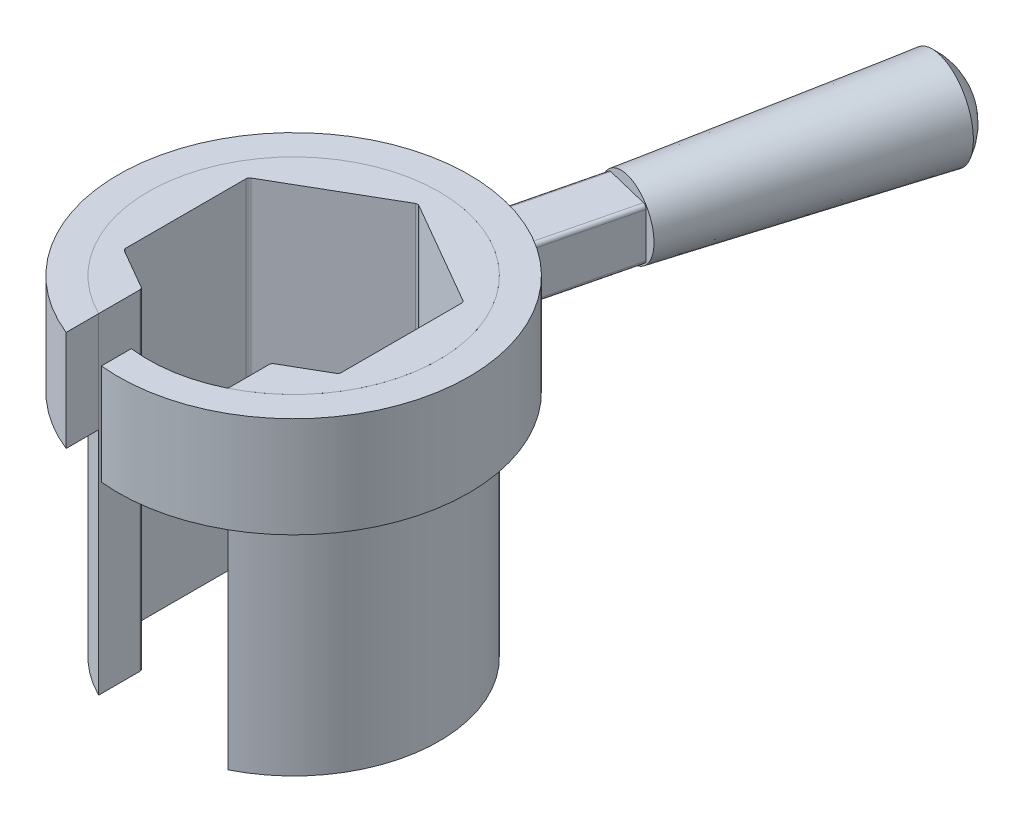
from build123d import *

# Parameters (mm, degrees)
EXTRUDE3_DEPTH                  = 46
EXTRUDE4_DEPTH                  = 14
SKETCH22_W                      = 7.200000000000002
SKETCH22_H                      = 7.199999999999999
EXTRUDE5_DEPTH                  = 14
EXTRUDE5_DIRECTION_2_REACH      = 75.07
EXTRUDE5_DIRECTION_2_END_RADIUS = 24.39
SKETCH23_R                      = 5.091168824543142
EXTRUDE6_DEPTH                  = 36
EXTRUDE6_DRAFT                  = -2.0000000000000044
DOME1_FACE_RADIUS               = 6.348316526
DOME1_HEIGHT                    = 3
CUT_EXTRUDE7_DEPTH              = 92.63173419897609
FILLET2_R                       = 0.5
FILLET3_R                       = 0.5


with BuildPart() as part:
    # Sketch20 → Extrude3 (new body)
    with BuildSketch(Plane(origin=(0, 0, 0), x_dir=(1, 0, 0), z_dir=(0, 1, 0))):
        with BuildLine():
            Line((-9, -12), (-8.999999999999998, -18.14007993367174))
            ThreePointArc((-8.999999999999998, -18.14007993367174), (5.74e-15, 20.25), (8.999999999999998, -18.14007993367174))
            Line((8.999999999999998, -18.14007993367174), (9, -12))
            ThreePointArc((9, -12), (9.2e-16, 15), (-9, -12))
        make_face()
    extrude(amount=EXTRUDE3_DEPTH)

    # Sketch24 → Cut-Extrude7 (cut, through all)
    with BuildSketch(Plane.XZ):
        Polygon((-15, 8.660254037844384), (-15.000000000000002, -8.660254037844384), (-1.98e-15, -17.32050807568877), (15, -8.660254037844378), (15, 8.660254037844389), (1.7e-15, 17.320508075688775), align=None)
    extrude(amount=-CUT_EXTRUDE7_DEPTH, mode=Mode.SUBTRACT)

    # Fillet3
    fillet3_edges = [part.edges().sort_by_distance(p)[0] for p in [
        (-9, 23, 12.124355652982139),
        (-15, 23, 8.660254037844384),
        (9, 23, 12.124355652982143),
        (15, 23, 8.660254037844389),
        (15, 23, -8.660254037844378),
        (-1.98e-15, 23, -17.32050807568877),
        (-15.000000000000002, 23, -8.660254037844384),
    ]]
    fillet(fillet3_edges, radius=FILLET3_R)


with BuildPart() as body_2:
    # Sketch21 → Extrude4 (new body)
    with BuildSketch(Plane(origin=(0, 45.998999999999995, 0), x_dir=(-1, 0, 0), z_dir=(0, 1, 0))):
        with BuildLine():
            Line((2.5, 20.095086464108586), (2.5, 24.261535400711967))
            ThreePointArc((2.5, 24.261535400711967), (-5.804889624821732, -23.689140052852004), (8.999999999999996, 22.668747208436557))
            Line((8.999999999999996, 22.668747208436557), (8.999999999999996, 18.14007993367174))
            ThreePointArc((8.999999999999996, 18.14007993367174), (-5.8324962609086, -19.39186652611056), (2.5, 20.095086464108586))
        make_face()
    extrude(amount=-EXTRUDE4_DEPTH)


with BuildPart() as body_3:
    # Sketch22 → Extrude5 (new body)
    with BuildSketch(Plane(origin=(5.8048896248217305, 45.998999999999995, -23.689140052852004), x_dir=(-0.9712644548114803, 0, -0.23800285464623744), z_dir=(0.23800285464623744, 0, -0.9712644548114803))):
        with Locations((0, -7)):
            Rectangle(SKETCH22_W, SKETCH22_H)
    extrude(amount=EXTRUDE5_DEPTH)

    # Extrude5 direction 2: up to this cylinder (the profile starts outside it)
    extrude5_direction_2_end = Plane(origin=(0, 38.999, 0), z_dir=(0, 1, 0)) * Cylinder(EXTRUDE5_DIRECTION_2_END_RADIUS, 199.92, mode=Mode.PRIVATE)
    # Sketch22 → Extrude5 direction 2 (add, up to the surface)
    with BuildSketch(Plane(origin=(5.8048896248217305, 45.998999999999995, -23.689140052852004), x_dir=(-0.9712644548114803, 0, -0.23800285464623744), z_dir=(0.23800285464623744, 0, -0.9712644548114803)), mode=Mode.PRIVATE) as extrude5_direction_2_sk1:
        with Locations((0, -7)):
            Rectangle(SKETCH22_W, SKETCH22_H)
    extrude5_direction_2_tool1 = extrude(extrude5_direction_2_sk1.sketch, amount=-EXTRUDE5_DIRECTION_2_REACH, mode=Mode.PRIVATE) - extrude5_direction_2_end
    add(extrude5_direction_2_tool1.solids().sort_by_distance((5.80489, 38.999, -23.68914))[0])
    add(extrude5_direction_2_tool1.solids().sort_by_distance((5.80489, 38.999, -23.68914))[1])


with BuildPart() as extrude6_tool:
    # Sketch23 → Extrude6 (with draft: the straight prism first)
    with BuildSketch(Plane(origin=(9.136929589869046, 0, -37.28684242021275), x_dir=(-0.9712644548114804, -1.6827536930173812e-15, -0.2380028546462371), z_dir=(0.2380028546462371, 0, -0.9712644548114804))):
        with Locations((0, 38.998999999999924)):
            Circle(SKETCH23_R)
    extrude(amount=EXTRUDE6_DEPTH)
    # Extrude6: the draft: its side faces are tilted about the plane it starts from
    extrude6_sides = [extrude6_tool.faces().sort_by_distance(p)[0] for p in [
        (18.365852286, 38.999, -53.557889893),
    ]]
    draft(extrude6_sides, Plane(origin=(9.136929589869046, 0, -37.28684242021275), x_dir=(-0.9712644548114804, -1.6827536930173812e-15, -0.2380028546462371), z_dir=(0.2380028546462371, 0, -0.9712644548114804)), EXTRUDE6_DRAFT)


with BuildPart() as body_3_1:
    add(body_3.part)

    # Extrude6: add extrude6_tool
    add(extrude6_tool.part)

    # Dome1: a dome of height H over a round flat face of radius A is a cap of a sphere of radius (A * A + H * H) / (2 * H)
    dome1_r = (DOME1_FACE_RADIUS * DOME1_FACE_RADIUS + DOME1_HEIGHT * DOME1_HEIGHT) / (2 * DOME1_HEIGHT)
    dome1_base = Plane((17.705032357, 38.999, -72.252362793), z_dir=(0.238002854646, 0, -0.971264454811))
    with Locations(dome1_base.offset(DOME1_HEIGHT - dome1_r)):
        dome1_ball = Sphere(dome1_r, mode=Mode.PRIVATE)
    add(split(dome1_ball, bisect_by=dome1_base, keep=Keep.TOP, mode=Mode.PRIVATE))

    # Fillet2
    fillet2_edges = [body_3_1.edges().sort_by_distance(p)[0] for p in [
        (10.935670926101846, 42.599, -29.501446402710464),
        (3.942566851459185, 42.599, -31.215066956163376),
        (3.9425668514591843, 35.398999999999994, -31.215066956163376),
        (10.935670926101844, 35.398999999999994, -29.501446402710464),
    ]]
    fillet(fillet2_edges, radius=FILLET2_R)


solid = Compound([part.part, body_2.part, body_3_1.part])
